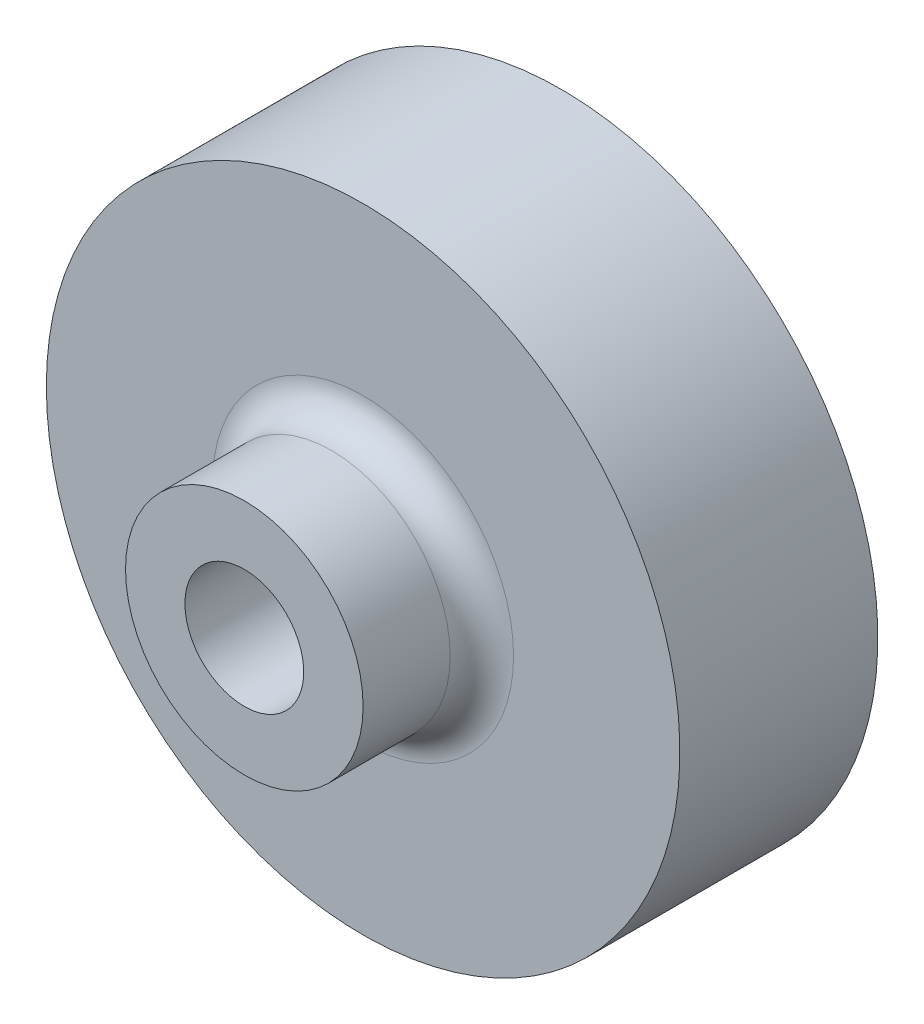
from build123d import *

# Parameters (mm, degrees)
CUT_EXTRUDE1_DEPTH = 26.4
CUT_EXTRUDE2_DEPTH = 22.225
FILLET1_R          = 2.54


with BuildPart() as part:
    # Sketch1 → Revolve1 (revolve)
    with BuildSketch(Plane(origin=(0, 0, 0), x_dir=(1, 0, 0), z_dir=(0, 1, 0))):
        Polygon((0, 0), (-9.525, 0), (-9.525, 9.525), (-25.4, 9.525), (-25.4, 25.4), (0, 25.4), align=None)
    revolve(axis=Axis((0, 0, -87.406759955), (0, 0, 1)))

    # Sketch2 → Cut-Extrude1 (cut, through all)
    with BuildSketch(Plane(origin=(0, 0, -25.4), x_dir=(-1, 0, 0), z_dir=(0, 0, -1))):
        with BuildLine():
            Line((-1.27, -4.590044254), (-1.27, 4.590044254))
            ThreePointArc((-1.27, 4.590044254), (-4.7625, 0), (-1.27, -4.590044254))
        make_face()
        with BuildLine():
            ThreePointArc((4.7625, 0), (3.790104303, 2.883836962), (1.27, 4.590044254))
            Line((1.27, 4.590044254), (1.27, -4.590044254))
            ThreePointArc((1.27, -4.590044254), (3.790104303, -2.883836962), (4.7625, 0))
        make_face()
    extrude(amount=-CUT_EXTRUDE1_DEPTH, mode=Mode.SUBTRACT)

    # Sketch3 → Cut-Extrude2 (cut)
    with BuildSketch(Plane.XY):
        with BuildLine():
            ThreePointArc((1.27, 4.590044254), (0, 4.7625), (-1.27, 4.590044254))
            Line((-1.27, 4.590044254), (-1.27, -4.590044254))
            ThreePointArc((-1.27, -4.590044254), (0, -4.7625), (1.27, -4.590044254))
            Line((1.27, -4.590044254), (1.27, 4.590044254))
        make_face()
    extrude(amount=-CUT_EXTRUDE2_DEPTH, mode=Mode.SUBTRACT)

    # Fillet1
    fillet1_edges = [part.edges().sort_by_distance(p)[0] for p in [
        (9.525, 0, -9.525),
    ]]
    fillet(fillet1_edges, radius=FILLET1_R)


solid = part.part
